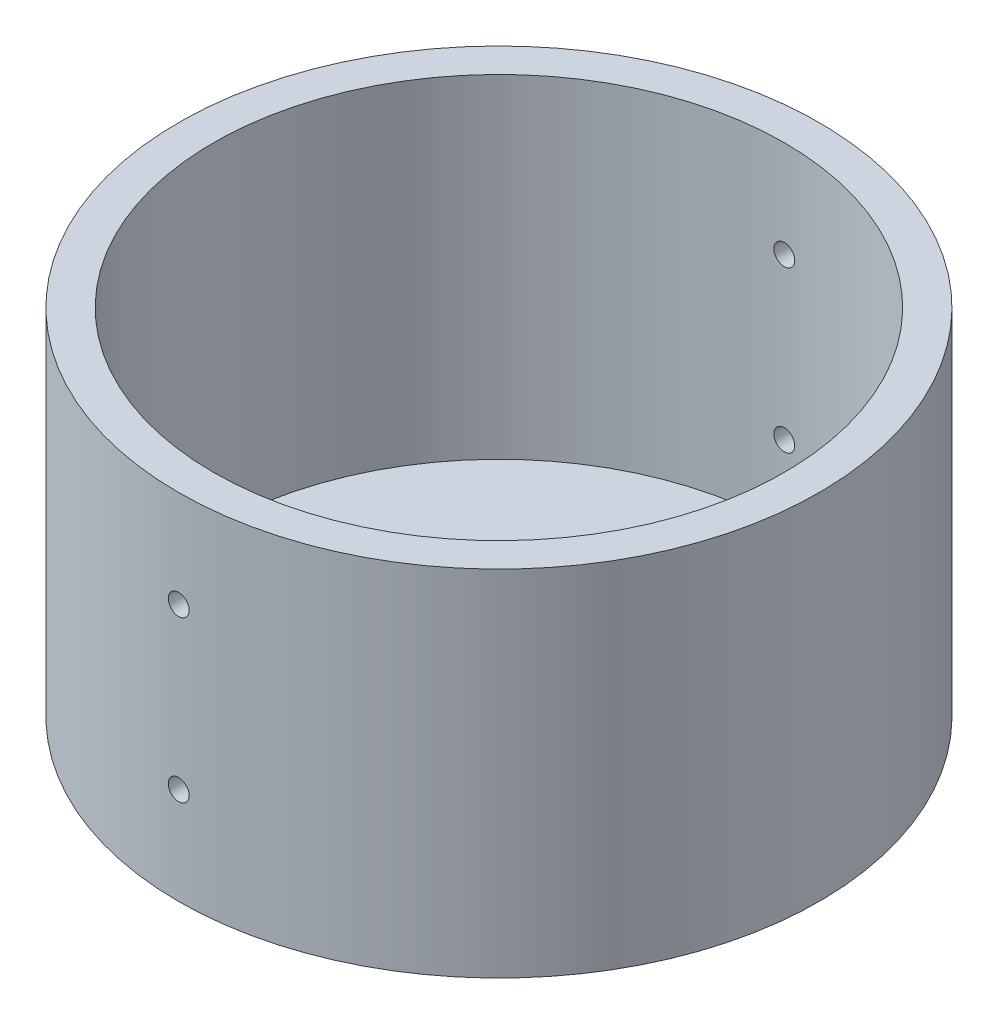
from build123d import *

# Parameters (mm, degrees)
SKETCH1_R                 = 45.95
BOSS_EXTRUDE1_DEPTH       = 3
SKETCH2_R                 = 45.95
SKETCH2_R_2               = 40.95
BOSS_EXTRUDE2_DEPTH       = 22.4
F_4_40_TAPPED_HOLE3_D     = 2.2606
F_4_40_TAPPED_HOLE3_DEPTH = 7.6
F_4_40_TAPPED_HOLE3_TIP   = 0.679152758
SKETCH11_R                = 1.5
CUT_EXTRUDE1_DEPTH        = 46.95
CUT_EXTRUDE1_DEPTH_BACK   = 46.95
SKETCH12_R                = 45.95
SKETCH12_R_2              = 40.95
BOSS_EXTRUDE3_DEPTH       = 25.4
SKETCH14_R                = 1.5
CUT_EXTRUDE2_DEPTH        = 46.95000011
CUT_EXTRUDE2_DEPTH_BACK   = 46.95000011
SKETCH15_R                = 3
CUT_EXTRUDE3_DEPTH        = 10


with BuildPart() as part:
    # Sketch1 → Boss-Extrude1 (new body)
    with BuildSketch(Plane(origin=(0, 0, 0), x_dir=(1, 0, 0), z_dir=(0, 1, 0))):
        Circle(SKETCH1_R)
    extrude(amount=BOSS_EXTRUDE1_DEPTH)

    # Sketch2 → Boss-Extrude2 (add)
    with BuildSketch(Plane(origin=(0, 3, 0), x_dir=(1, 0, 0), z_dir=(0, 1, 0))):
        Circle(SKETCH2_R)
        Circle(SKETCH2_R_2, mode=Mode.SUBTRACT)
    extrude(amount=BOSS_EXTRUDE2_DEPTH)

    # #4-40 Tapped Hole3
    with Locations(Plane(origin=(0, 0, 0), x_dir=(-1, 0, 0), z_dir=(0, -1, 0))):
        with Locations((9.5, 0), (4.75, -8.227241336), (-4.75, -8.227241336), (-9.5, 0), (-4.75, 8.227241336), (4.75, 8.227241336)):
            Hole(F_4_40_TAPPED_HOLE3_D / 2, depth=F_4_40_TAPPED_HOLE3_DEPTH)
            with Locations((0, 0, -(F_4_40_TAPPED_HOLE3_DEPTH + F_4_40_TAPPED_HOLE3_TIP / 2))):  # 118° drill point
                Cone(0, F_4_40_TAPPED_HOLE3_D / 2, F_4_40_TAPPED_HOLE3_TIP, mode=Mode.SUBTRACT)

    # Sketch11 → Cut-Extrude1 (cut, two sides)
    with BuildSketch(Plane.XY) as cut_extrude1_sk:
        with Locations((0, 13.9)):
            Circle(SKETCH11_R)
        with Locations((0, -13.9)):
            Circle(SKETCH11_R)
    extrude(amount=CUT_EXTRUDE1_DEPTH, mode=Mode.SUBTRACT)
    extrude(cut_extrude1_sk.sketch, amount=-CUT_EXTRUDE1_DEPTH_BACK, mode=Mode.SUBTRACT)

    # Sketch12 → Boss-Extrude3 (add)
    with BuildSketch(Plane(origin=(0, 25.4, 0), x_dir=(1, 0, 0), z_dir=(0, 1, 0))):
        Circle(SKETCH12_R)
        Circle(SKETCH12_R_2, mode=Mode.SUBTRACT)
    extrude(amount=BOSS_EXTRUDE3_DEPTH)

    # Sketch14 → Cut-Extrude2 (cut, two sides)
    with BuildSketch(Plane.XY) as cut_extrude2_sk:
        with Locations((0, 36.9)):
            Circle(SKETCH14_R)
    extrude(amount=CUT_EXTRUDE2_DEPTH, mode=Mode.SUBTRACT)
    extrude(cut_extrude2_sk.sketch, amount=-CUT_EXTRUDE2_DEPTH_BACK, mode=Mode.SUBTRACT)

    # Sketch15 → Cut-Extrude3 (cut)
    with BuildSketch(Plane(origin=(0, 3, 0), x_dir=(1, 0, 0), z_dir=(0, 1, 0))):
        Circle(SKETCH15_R)
    extrude(amount=-CUT_EXTRUDE3_DEPTH, mode=Mode.SUBTRACT)


solid = part.part
